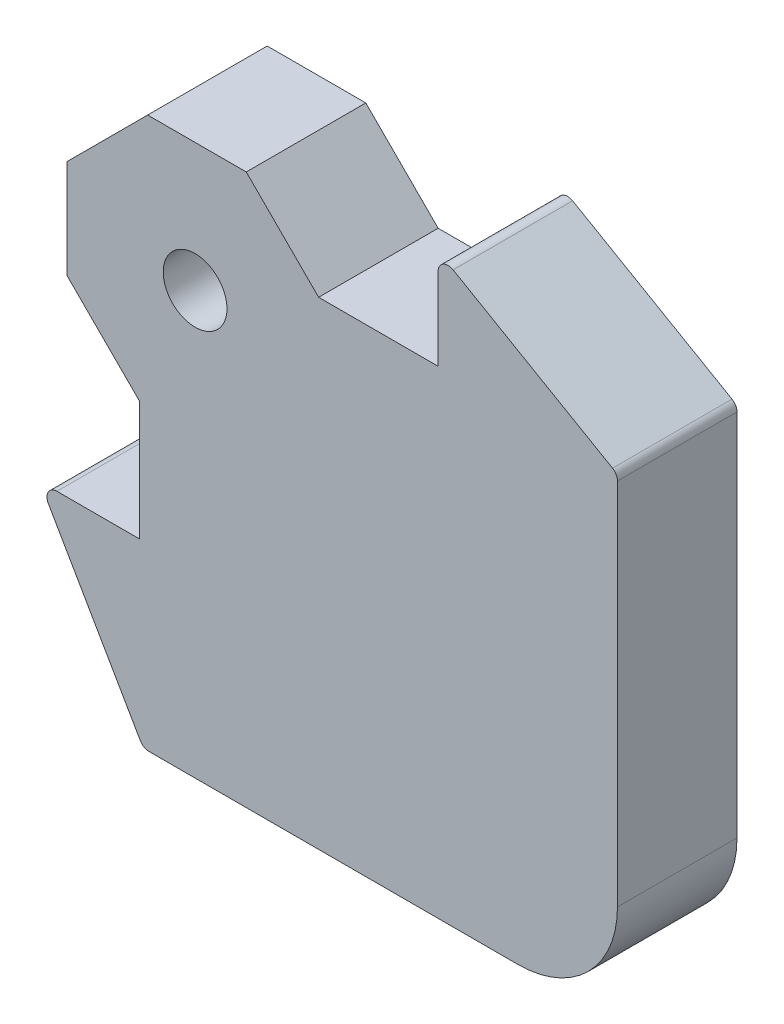
from build123d import *

# Parameters (mm, degrees)
SKETCH1_R           = 1.6
BOSS_EXTRUDE1_DEPTH = 3
BOSS_EXTRUDE2_DEPTH = 3
FILLET1_R           = 0.5
CUT_EXTRUDE1_REACH  = 8
CHAMFER1_SIZE       = 3.5


with BuildPart() as part:
    # Sketch1 → Boss-Extrude1 (new body, symmetric)
    with BuildSketch(Plane.XY):
        Polygon((0, 0), (-21.213203436, 0), (0, 21.213203436), align=None)
        with Locations((-6.2, 6.2)):
            Circle(SKETCH1_R, mode=Mode.SUBTRACT)
    extrude(amount=BOSS_EXTRUDE1_DEPTH, both=True)

    # Sketch2 → Boss-Extrude2 (add, symmetric)
    with BuildSketch(Plane.XY):
        with BuildLine():
            Line((-9, 0), (-9, -6))
            Line((-9, -6), (-14, -6))
            Line((-14, -6), (-8.803847577, -15))
            Line((-8.803847577, -15), (10, -15))
            ThreePointArc((10, -15), (13.535533906, -13.535533906), (15, -10))
            Line((15, -10), (15, 8.803847577))
            Line((15, 8.803847577), (6, 14))
            Line((6, 14), (6, 9))
            Line((6, 9), (0, 9))
            Line((0, 9), (0, 0))
            Line((0, 0), (-9, 0))
        make_face()
    extrude(amount=BOSS_EXTRUDE2_DEPTH, both=True)

    # Fillet1
    fillet1_edges = [part.edges().sort_by_distance(p)[0] for p in [
        (-14, -6, 0),
        (-8.803847577, -15, 0),
        (15, 8.803847577, 0),
        (6, 14, 0),
    ]]
    fillet(fillet1_edges, radius=FILLET1_R)

    # Sketch4 → Cut-Extrude1 (cut, up to next)
    with BuildSketch(Plane.XY.offset(3), mode=Mode.PRIVATE) as cut_extrude1_sk1:
        Polygon((0, 9), (-6.106601718, 15.106601718), (0, 21.213203436), align=None)
    cut_extrude1_tool1 = extrude(cut_extrude1_sk1.sketch, amount=-CUT_EXTRUDE1_REACH, mode=Mode.PRIVATE) & part.part
    add(cut_extrude1_tool1.solids().sort_by_distance((-2.035534, 15.106602, 3))[0], mode=Mode.SUBTRACT)
    # Sketch4 → Cut-Extrude1 (cut, up to next)
    with BuildSketch(Plane.XY.offset(3), mode=Mode.PRIVATE) as cut_extrude1_sk2:
        Polygon((-21.213203436, 0), (-15.106601718, 6.106601718), (-9, 0), align=None)
    cut_extrude1_tool2 = extrude(cut_extrude1_sk2.sketch, amount=-CUT_EXTRUDE1_REACH, mode=Mode.PRIVATE) & part.part
    add(cut_extrude1_tool2.solids().sort_by_distance((-15.106602, 2.035534, 3))[0], mode=Mode.SUBTRACT)

    # Chamfer1
    chamfer1_edges = [part.edges().sort_by_distance(p)[0] for p in [
        (-6.106601718, 15.106601718, 0),
        (-15.106601718, 6.106601718, 0),
    ]]
    chamfer(chamfer1_edges, length=CHAMFER1_SIZE)


solid = part.part
